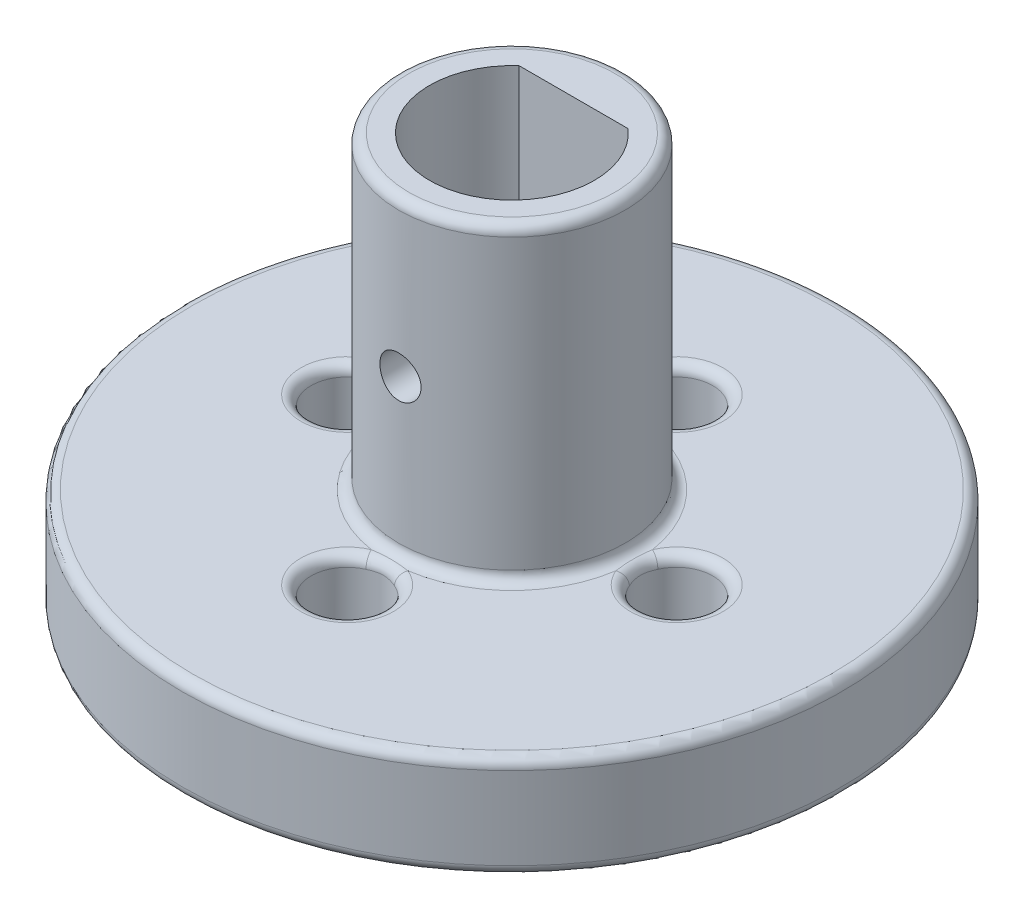
from build123d import *

# Parameters (mm, degrees)
SKETCH1_R               = 16
BOSS_EXTRUDE1_DEPTH     = 5
SKETCH3_R               = 5.5
SKETCH3_R_2             = 4
BOSS_EXTRUDE2_DEPTH     = 15
SKETCH4_W               = 6
SKETCH4_H               = 1.5
BOSS_EXTRUDE3_DEPTH     = 15
SKETCH5_R               = 1.75
CUT_EXTRUDE1_DEPTH      = 6
FILLET1_R               = 0.5
SKETCH6_R               = 1
CUT_EXTRUDE2_DEPTH      = 17
CUT_EXTRUDE2_DEPTH_BACK = 17
FILLET2_R               = 0.5
SKETCH7_R               = 4
BOSS_EXTRUDE4_DEPTH     = 5
FILLET3_R               = 0.5


with BuildPart() as part:
    # Sketch1 → Boss-Extrude1 (new body)
    with BuildSketch(Plane(origin=(0, 0, 0), x_dir=(1, 0, 0), z_dir=(0, 1, 0))):
        Circle(SKETCH1_R)
    extrude(amount=BOSS_EXTRUDE1_DEPTH)

    # Sketch3 → Boss-Extrude2 (add)
    with BuildSketch(Plane(origin=(0, 5, 0), x_dir=(1, 0, 0), z_dir=(0, 1, 0))):
        Circle(SKETCH3_R)
        Circle(SKETCH3_R_2, mode=Mode.SUBTRACT)
    extrude(amount=BOSS_EXTRUDE2_DEPTH)

    # Sketch4 → Boss-Extrude3 (add)
    with BuildSketch(Plane(origin=(0, 20, 0), x_dir=(1, 0, 0), z_dir=(0, 1, 0))):
        with Locations((0, 3.75)):
            Rectangle(SKETCH4_W, SKETCH4_H)
    extrude(amount=-BOSS_EXTRUDE3_DEPTH)

    # Sketch5 → Cut-Extrude1 (cut, through all)
    with BuildSketch(Plane(origin=(0, 5, 0), x_dir=(1, 0, 0), z_dir=(0, 1, 0))):
        with Locations((0, 8)):
            Circle(SKETCH5_R)
        with Locations((8, 0)):
            Circle(SKETCH5_R)
        with Locations((0, -8)):
            Circle(SKETCH5_R)
        with Locations((-8, 0)):
            Circle(SKETCH5_R)
    extrude(amount=-CUT_EXTRUDE1_DEPTH, mode=Mode.SUBTRACT)

    # Fillet1
    fillet1_edges = [part.edges().sort_by_distance(p)[0] for p in [
        (-16, 0, 0),
        (-16, 5, 0),
        (-5.5, 20, 0),
        (-5.5, 5, 0),
    ]]
    fillet(fillet1_edges, radius=FILLET1_R)

    # Sketch6 → Cut-Extrude2 (cut, two sides)
    with BuildSketch(Plane.XY) as cut_extrude2_sk:
        with Locations((0, 12.5)):
            Circle(SKETCH6_R)
    extrude(amount=CUT_EXTRUDE2_DEPTH, mode=Mode.SUBTRACT)
    extrude(cut_extrude2_sk.sketch, amount=-CUT_EXTRUDE2_DEPTH_BACK, mode=Mode.SUBTRACT)

    # Fillet2
    fillet2_edges = [part.edges().sort_by_distance(p)[0] for p in [
        (-1.75, 5, -8),
        (6.25, 5, 0),
        (-1.75, 5, 8),
        (-9.75, 5, 0),
    ]]
    fillet(fillet2_edges, radius=FILLET2_R)

    # Sketch7 → Boss-Extrude4 (add)
    with BuildSketch(Plane.XZ):
        Circle(SKETCH7_R)
    extrude(amount=BOSS_EXTRUDE4_DEPTH)

    # Fillet3
    fillet3_edges = [part.edges().sort_by_distance(p)[0] for p in [
        (-4, 0, 0),
        (-4, -5, 0),
    ]]
    fillet(fillet3_edges, radius=FILLET3_R)


solid = part.part
